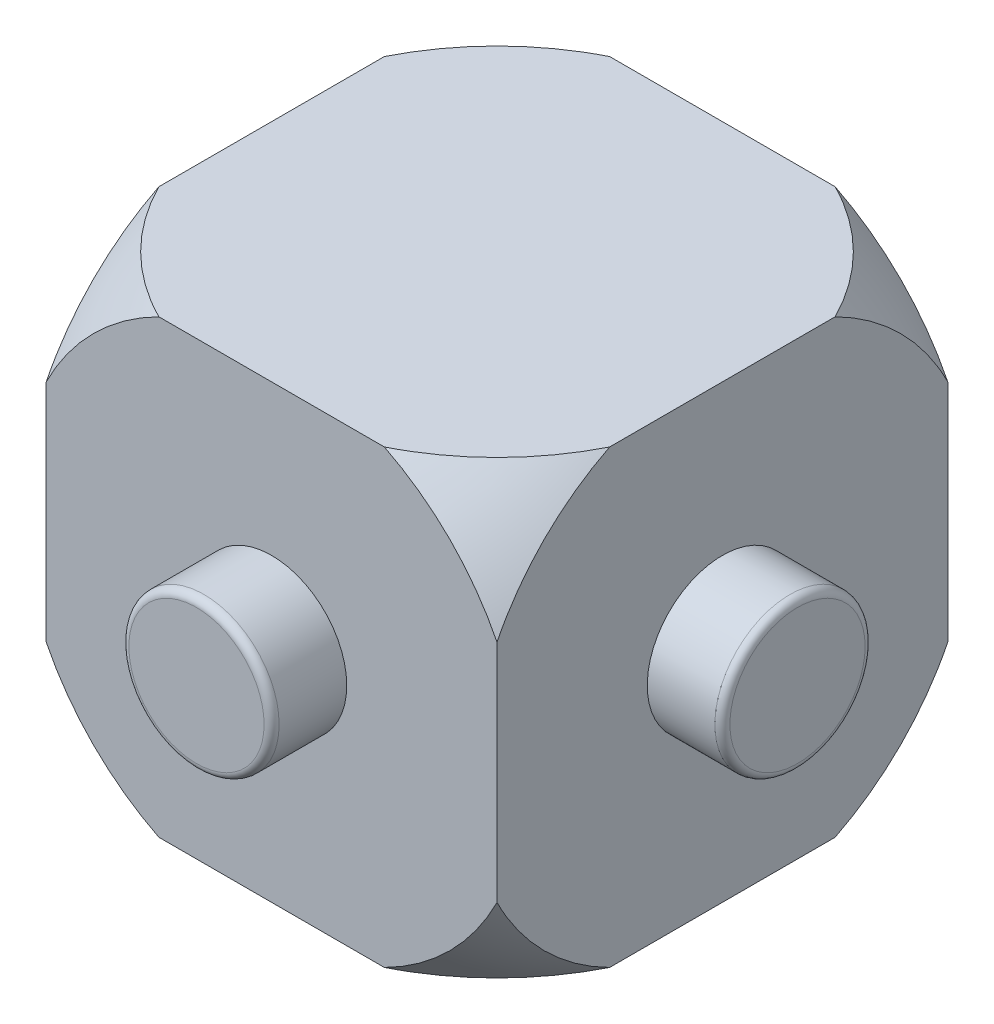
from build123d import *

# Parameters (mm, degrees)
SKETCH_1_W      = 6
SKETCH_1_H      = 6
EXTRUDE_1_DEPTH = 3
SKETCH_2_R      = 1
EXTRUDE_2_DEPTH = 4
SKETCH_3_R      = 1
EXTRUDE_3_DEPTH = 4
FILLET_1_R      = 0.1


with BuildPart() as part:
    # 草图1 → 凸台-拉伸1 (new, symmetric)
    with BuildSketch(Plane.XY):
        Rectangle(SKETCH_1_W, SKETCH_1_H)
    extrude(amount=EXTRUDE_1_DEPTH, both=True)

    # 草图4 → 切除-旋转4 (revolve, cut)
    with BuildSketch(Plane(origin=(0, 0, 0), x_dir=(1, 0, 0), z_dir=(0, 1, 0))):
        with BuildLine():
            Line((0, -4.5), (0, -6.318562405))
            Line((0, -6.318562405), (-7, -6.318562405))
            Line((-7, -6.318562405), (-7, 6.288804718))
            Line((-7, 6.288804718), (0, 6.288804718))
            Line((0, 6.288804718), (0, 4.5))
            ThreePointArc((0, 4.5), (-4.5, 0), (0, -4.5))
        make_face()
    revolve(axis=Axis((0, 0, -4.5), (0, 0, 1)), mode=Mode.SUBTRACT)

    # 草图2 → 凸台-拉伸2 (add, symmetric)
    with BuildSketch(Plane.XY):
        Circle(SKETCH_2_R)
    extrude(amount=EXTRUDE_2_DEPTH, both=True)

    # 草图3 → 凸台-拉伸3 (add, symmetric)
    with BuildSketch(Plane(origin=(0, 0, 0), x_dir=(0, 0, -1), z_dir=(1, 0, 0))):
        Circle(SKETCH_3_R)
    extrude(amount=EXTRUDE_3_DEPTH, both=True)

    # 圆角1
    fillet_1_edges = [part.edges().sort_by_distance(p)[0] for p in [
        (4, 0, 1),
        (-1, 0, -4),
        (-4, 0, 1),
        (-1, 0, 4),
    ]]
    fillet(fillet_1_edges, radius=FILLET_1_R)


solid = part.part
